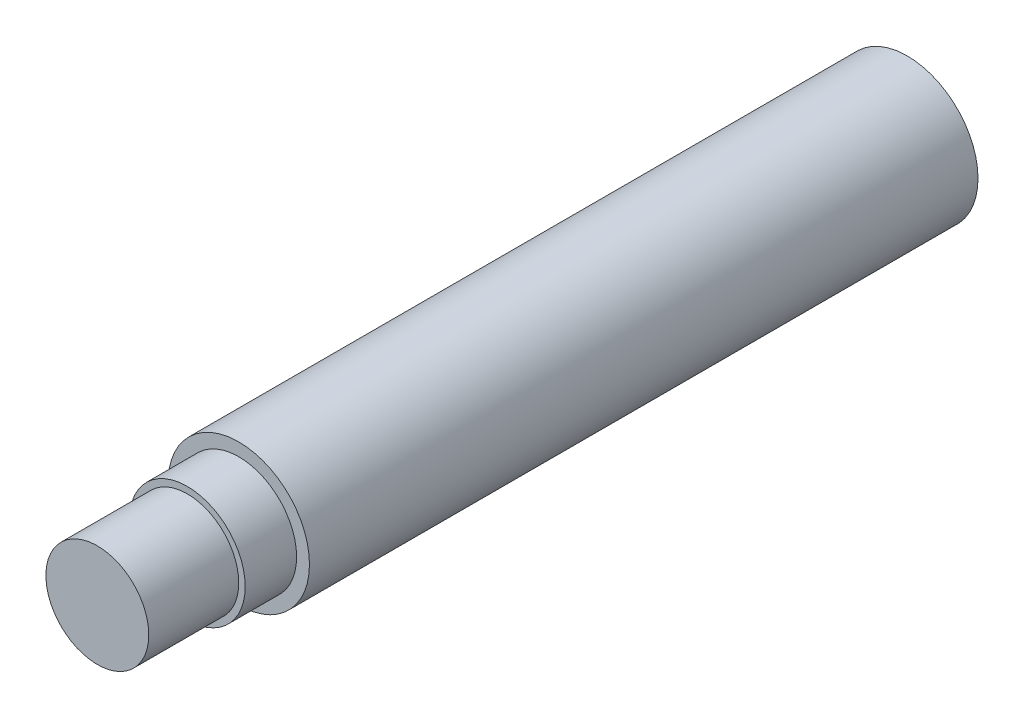
from build123d import *

# Parameters (mm, degrees)
TAP_DRILL_FOR_M8X1_0_TAP1_D     = 7
TAP_DRILL_FOR_M8X1_0_TAP1_DEPTH = 6
TAP_DRILL_FOR_M8X1_0_TAP1_TIP   = 2.103012167


with BuildPart() as part:
    # Sketch1 → Revolve1 (revolve)
    with BuildSketch(Plane(origin=(0, 0, 0), x_dir=(0, 0, -1), z_dir=(1, 0, 0))):
        Polygon((0, 0), (22.670726421, 0), (24, 2.5), (63, 2.5), (63, 5.5), (11, 5.5), (11, 4.5), (7, 4.5), (7, 4), (0, 4), align=None)
    revolve(axis=Axis((0, 0, 0), (0, 0, -1)))

    # Tap Drill for M8x1.0 Tap1
    with Locations(Plane(origin=(0, 0, -63), x_dir=(-1, 0, 0), z_dir=(0, 0, -1))):
        with Locations((0, 0)):
            Hole(TAP_DRILL_FOR_M8X1_0_TAP1_D / 2, depth=TAP_DRILL_FOR_M8X1_0_TAP1_DEPTH)
            with Locations((0, 0, -(TAP_DRILL_FOR_M8X1_0_TAP1_DEPTH + TAP_DRILL_FOR_M8X1_0_TAP1_TIP / 2))):  # 118° drill point
                Cone(0, TAP_DRILL_FOR_M8X1_0_TAP1_D / 2, TAP_DRILL_FOR_M8X1_0_TAP1_TIP, mode=Mode.SUBTRACT)


solid = part.part
